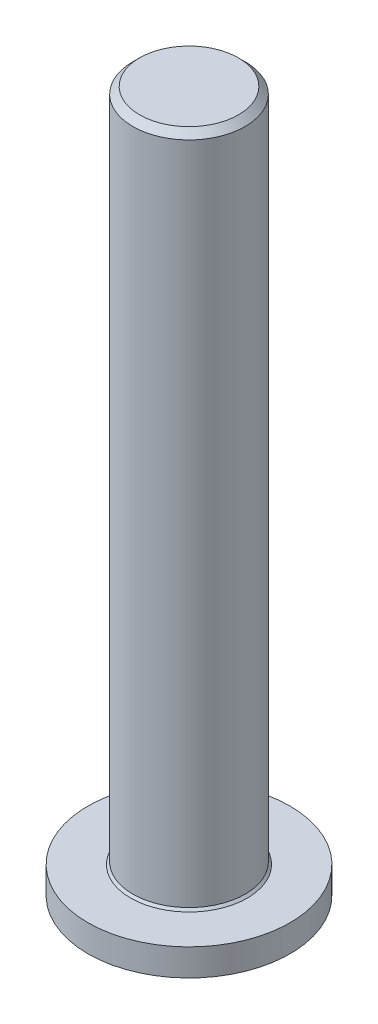
from build123d import *

# Parameters (mm, degrees)
SKETCH2_R           = 4.5
BOSS_EXTRUDE1_DEPTH = 1.5
SKETCH3_R           = 2.5
BOSS_EXTRUDE2_DEPTH = 30
CHAMFER1_SIZE       = 0.1
CHAMFER2_SIZE       = 0.75
CHAMFER2_SIZE2      = 0.3
CUT_EXTRUDE1_DEPTH  = 3
CHAMFER3_SIZE       = 0.3


with BuildPart() as part:
    # Sketch2 → Boss-Extrude1 (new body)
    with BuildSketch(Plane(origin=(0, 0, 0), x_dir=(1, 0, 0), z_dir=(0, 1, 0))):
        Circle(SKETCH2_R)
    extrude(amount=BOSS_EXTRUDE1_DEPTH)

    # Sketch3 → Boss-Extrude2 (add)
    with BuildSketch(Plane(origin=(0, 1.5, 0), x_dir=(1, 0, 0), z_dir=(0, 1, 0))):
        Circle(SKETCH3_R)
    extrude(amount=BOSS_EXTRUDE2_DEPTH)

    # Chamfer1
    chamfer1_edges = [part.edges().sort_by_distance(p)[0] for p in [
        (-2.5, 1.5, 0),
    ]]
    chamfer(chamfer1_edges, length=CHAMFER1_SIZE)

    # Chamfer2
    chamfer2_edges = [part.edges().sort_by_distance(p)[0] for p in [
        (-4.5, 0, 0),
    ]]
    chamfer2_side = [part.faces().sort_by_distance(p)[0] for p in [
        (0, 0, 0),
    ]]
    chamfer(chamfer2_edges, length=CHAMFER2_SIZE, length2=CHAMFER2_SIZE2, reference=chamfer2_side[0])

    # Sketch4 → Cut-Extrude1 (cut)
    with BuildSketch(Plane.XZ):
        Polygon((-0.422737578, 1.679670486), (-1.6660061, 0.473733761), (-1.243268521, -1.205936725), (0.422737578, -1.679670486), (1.6660061, -0.473733761), (1.243268521, 1.205936725), align=None)
    extrude(amount=-CUT_EXTRUDE1_DEPTH, mode=Mode.SUBTRACT)

    # Chamfer3
    chamfer3_edges = [part.edges().sort_by_distance(p)[0] for p in [
        (-2.5, 31.5, 0),
    ]]
    chamfer(chamfer3_edges, length=CHAMFER3_SIZE)


solid = part.part
